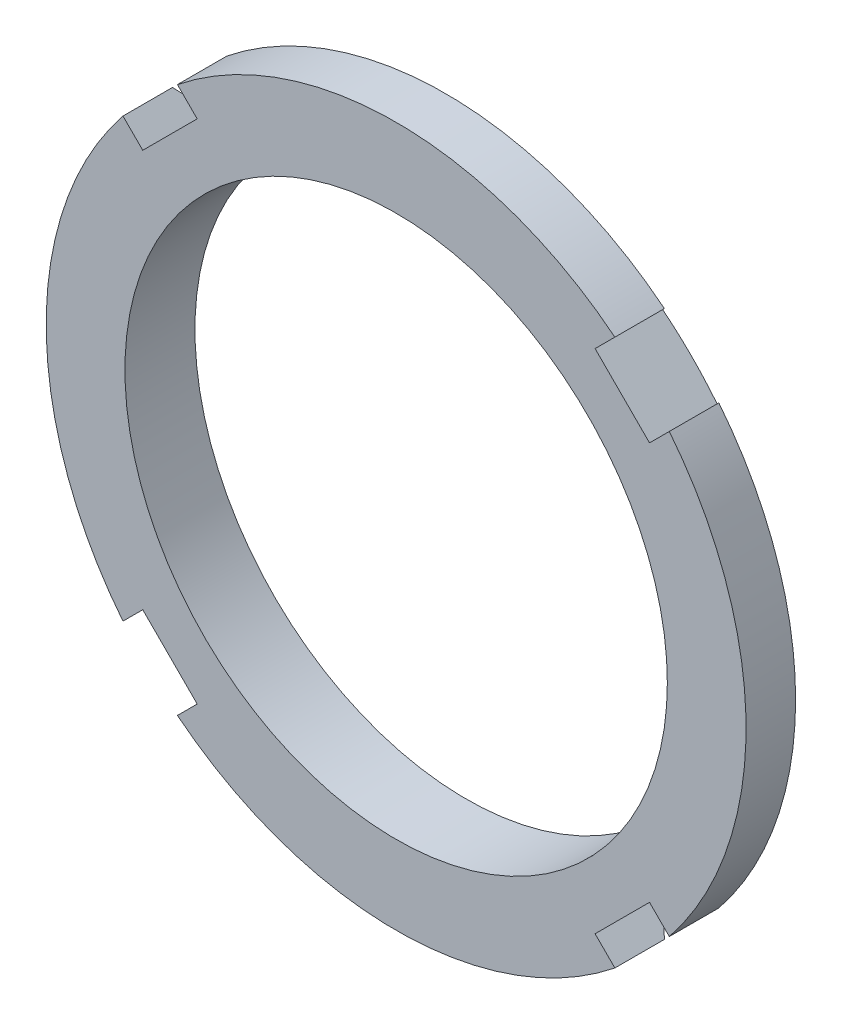
from build123d import *

# Parameters (mm, degrees)
SKETCH1_R          = 50
SKETCH1_R_2        = 38.75
EXTRUDE1_DEPTH     = 10
CUT_EXTRUDE1_DEPTH = 11
CIRPATTERN1_COUNT  = 4


with BuildPart() as part:
    # Sketch1 → Extrude1 (new body)
    with BuildSketch(Plane.XY):
        Circle(SKETCH1_R)
        Circle(SKETCH1_R_2, mode=Mode.SUBTRACT)
    extrude(amount=EXTRUDE1_DEPTH)

    # Sketch2 → Cut-Extrude1 (cut, through all)
    with BuildSketch(Plane.XY.offset(10)):
        with BuildLine():
            Line((31.25170097, 39.029875563), (28.425692604, 36.203867197))
            Line((28.425692604, 36.203867197), (36.203867197, 28.425692604))
            Line((36.203867197, 28.425692604), (39.029875563, 31.25170097))
            ThreePointArc((39.029875563, 31.25170097), (35.355339059, 35.355339059), (31.25170097, 39.029875563))
        make_face()
    cut_extrude1 = extrude(amount=-CUT_EXTRUDE1_DEPTH, mode=Mode.SUBTRACT)

    # CirPattern1: Cut-Extrude1 ×4 about axis
    cirpattern1_axis = Axis((0, 0, 0), (0, 0, 1))
    for i in range(1, CIRPATTERN1_COUNT):
        add(cut_extrude1.rotate(cirpattern1_axis, i * 360 / CIRPATTERN1_COUNT), mode=Mode.SUBTRACT)

    # Sketch3 → Cut-Revolve1 (revolve, cut)
    with BuildSketch(Plane(origin=(0, 0, 0), x_dir=(1, 0, 0), z_dir=(0, 1, 0))):
        Polygon((50, 0), (45.5, 0), (50, -2.922334169), align=None)
    revolve(axis=Axis((0, 0, 0), (0, 0, -1)), mode=Mode.SUBTRACT)


solid = part.part
